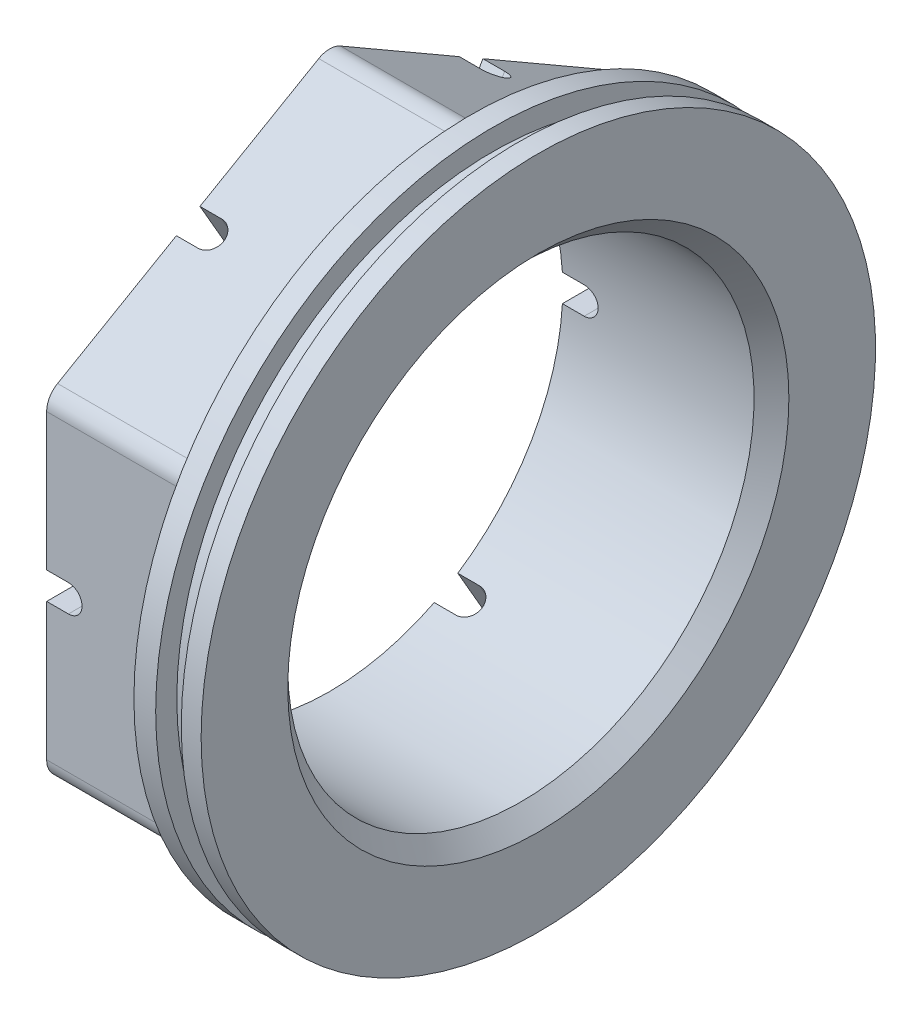
from build123d import *

# Parameters (mm, degrees)
CUT_EXTRUDE1_START = -20.6375
SKETCH3_R          = 49.1871
CUT_EXTRUDE1_DEPTH = 20.6375
FILLET3_R          = 3.175
CHAMFER1_SIZE      = 2.54
CUT_EXTRUDE2_DEPTH = 91.4621
CIRPATTERN1_COUNT  = 6


with BuildPart() as part:
    # Sketch2 → Revolve1 (revolve)
    with BuildSketch(Plane.XY):
        Polygon((-25.6794, 49.1871), (-6.6294, 49.1871), (-1.8669, 49.1871), (-1.8669, 46.105572), (1.8669, 46.105572), (1.8669, 49.1871), (4.7625, 49.1871), (4.7625, 34.0106), (-25.6794, 34.0106), align=None)
    revolve(axis=Axis((0, 0, 0), (1, 0, 0)))

    # Sketch3 → Cut-Extrude1 (cut)
    with BuildSketch(Plane.ZY.offset(25.6794).offset(CUT_EXTRUDE1_START)):
        Circle(SKETCH3_R)
        Polygon((0, 47.660264722), (41.275, 23.830132361), (41.275, -23.830132361), (0, -47.660264722), (-41.275, -23.830132361), (-41.275, 23.830132361), align=None, mode=Mode.SUBTRACT)
    extrude(amount=CUT_EXTRUDE1_DEPTH, mode=Mode.SUBTRACT)

    # Fillet3
    fillet3_edges = [part.edges().sort_by_distance(p)[0] for p in [
        (-15.36065, -23.830132361, 41.275),
        (-15.36065, 23.830132361, 41.275),
        (-15.36065, 47.660264722, 0),
        (-15.36065, 23.830132361, -41.275),
        (-15.36065, -23.830132361, -41.275),
        (-15.36065, -47.660264722, 0),
    ]]
    fillet(fillet3_edges, radius=FILLET3_R)

    # Chamfer1
    chamfer1_edges = [part.edges().sort_by_distance(p)[0] for p in [
        (4.7625, -34.0106, 0),
    ]]
    chamfer(chamfer1_edges, length=CHAMFER1_SIZE)

    # Sketch4 → Cut-Extrude2 (cut, through all)
    with BuildSketch(Plane(origin=(0, 0, -41.275), x_dir=(-1, 0, 0), z_dir=(0, 0, -1))):
        with BuildLine():
            Line((25.6794, -1.984502), (25.6794, 1.984502))
            Line((25.6794, 1.984502), (22.5044, 1.984502))
            ThreePointArc((22.5044, 1.984502), (20.519898, 0), (22.5044, -1.984502))
            Line((22.5044, -1.984502), (25.6794, -1.984502))
        make_face()
    cut_extrude2 = extrude(amount=-CUT_EXTRUDE2_DEPTH, mode=Mode.SUBTRACT)

    # CirPattern1: Cut-Extrude2 ×6 about axis
    cirpattern1_axis = Axis((0, 0, 0), (1, 0, 0))
    for i in range(1, CIRPATTERN1_COUNT):
        add(cut_extrude2.rotate(cirpattern1_axis, i * 360 / CIRPATTERN1_COUNT), mode=Mode.SUBTRACT)


solid = part.part
